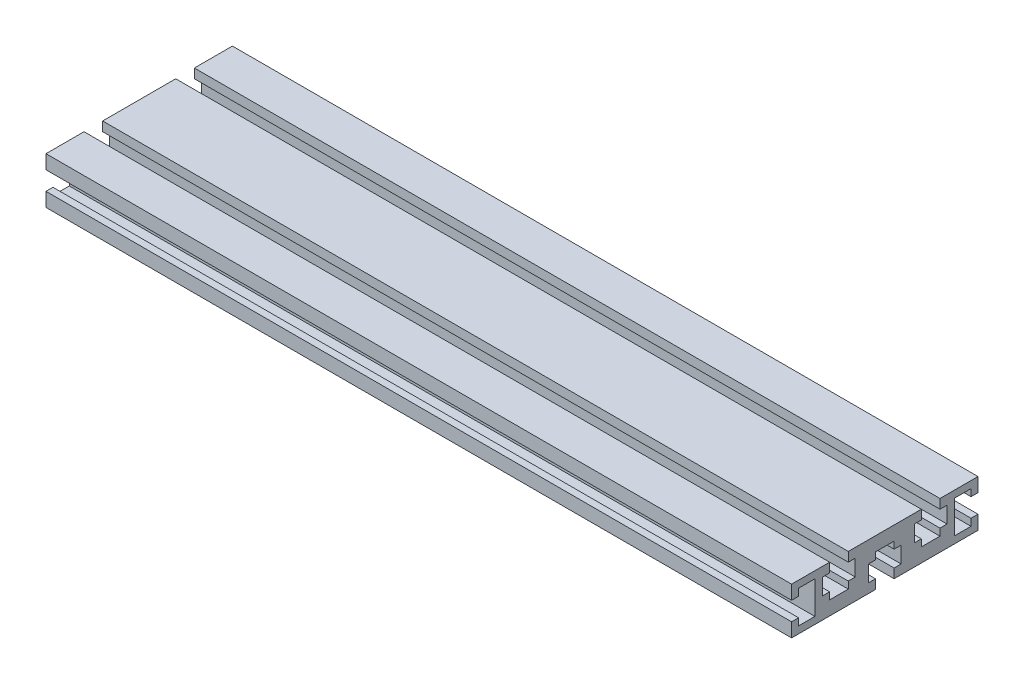
from build123d import *

# Parameters (mm, degrees)
BOSS_EXTRUDE1_DEPTH = 320


with BuildPart() as part:
    # Sketch1 → Boss-Extrude1 (new body)
    with BuildSketch(Plane(origin=(0, 0, 0), x_dir=(0, 0, -1), z_dir=(1, 0, 0))):
        Polygon((-4, -10.595398602), (-40, -10.595398602), (-40, -4.595398602), (-37, -4.595398602), (-37, -7.595398602), (-30, -7.595398602), (-30, 6.404601398), (-37, 6.404601398), (-37, 3.404601398), (-40, 3.404601398), (-40, 9.404601398), (-23.683229509, 9.404601398), (-23.683229509, 5.404601398), (-26.683229509, 5.404601398), (-26.683229509, -1.595398602), (-23.683229509, -1.595398602), (-23.683229509, -4.595398602), (-15.683229509, -4.595398602), (-15.683229509, -1.595398602), (-12.683229509, -1.595398602), (-12.683229509, 5.404601398), (-15.683229509, 5.404601398), (-15.683229509, 9.404601398), (15.683229509, 9.404601398), (15.683229509, 5.404601398), (12.683229509, 5.404601398), (12.683229509, -1.595398602), (15.683229509, -1.595398602), (15.683229509, -4.595398602), (23.683229509, -4.595398602), (23.683229509, -1.595398602), (26.683229509, -1.595398602), (26.683229509, 5.404601398), (23.683229509, 5.404601398), (23.683229509, 9.404601398), (40, 9.404601398), (40, 3.404601398), (37, 3.404601398), (37, 6.404601398), (30, 6.404601398), (30, -7.595398602), (37, -7.595398602), (37, -4.595398602), (40, -4.595398602), (40, -10.595398602), (4, -10.595398602), (4, -6.595398602), (7, -6.595398602), (7, 0.404601398), (4, 0.404601398), (4, 3.404601398), (-4, 3.404601398), (-4, 0.404601398), (-7, 0.404601398), (-7, -6.595398602), (-4, -6.595398602), align=None)
    extrude(amount=BOSS_EXTRUDE1_DEPTH)


solid = part.part
